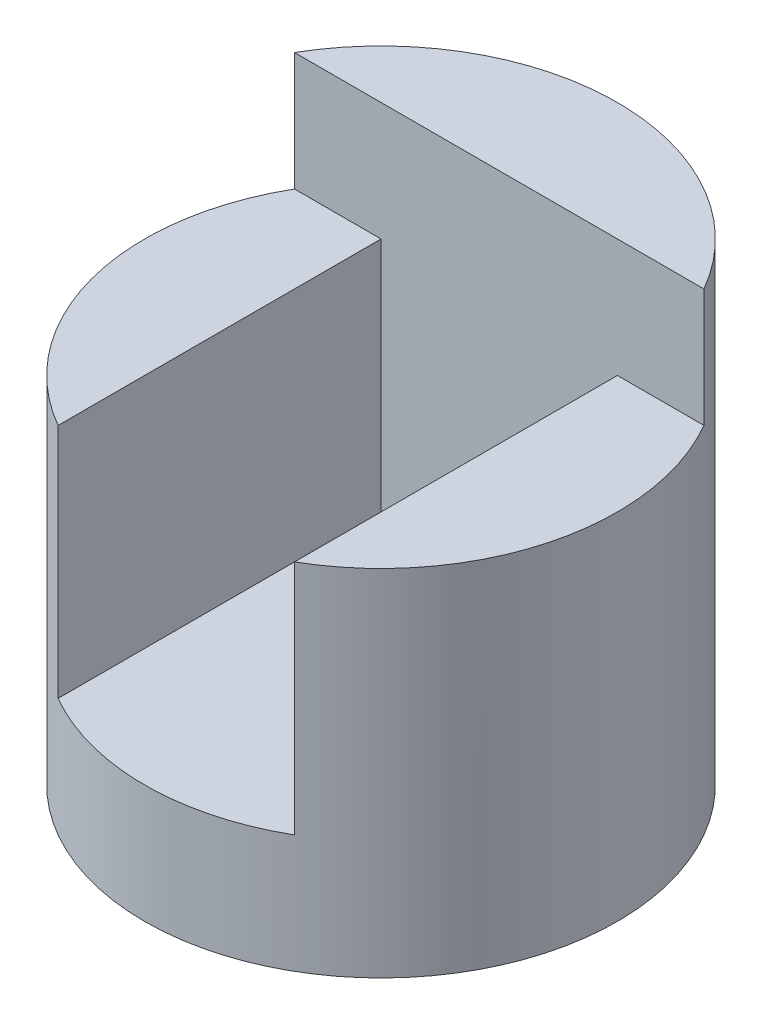
from build123d import *

# Parameters (mm, degrees)
SKETCH1_R               = 2
BOSS_EXTRUDE1_DEPTH     = 4
CUT_EXTRUDE1_DEPTH      = 3
CUT_EXTRUDE1_DEPTH_BACK = 1


with BuildPart() as part:
    # Sketch1 → Boss-Extrude1 (new body)
    with BuildSketch(Plane(origin=(0, 0, 0), x_dir=(1, 0, 0), z_dir=(0, 1, 0))):
        Circle(SKETCH1_R)
    extrude(amount=BOSS_EXTRUDE1_DEPTH)

    # Sketch2 → Cut-Extrude1 (cut, two sides)
    with BuildSketch(Plane.XY) as cut_extrude1_sk:
        Polygon((-2, 4), (2, 4), (2, 3), (1, 3), (1, 1), (-1, 1), (-1, 3), (-2, 3), align=None)
    extrude(amount=CUT_EXTRUDE1_DEPTH, mode=Mode.SUBTRACT)
    extrude(cut_extrude1_sk.sketch, amount=-CUT_EXTRUDE1_DEPTH_BACK, mode=Mode.SUBTRACT)


solid = part.part
